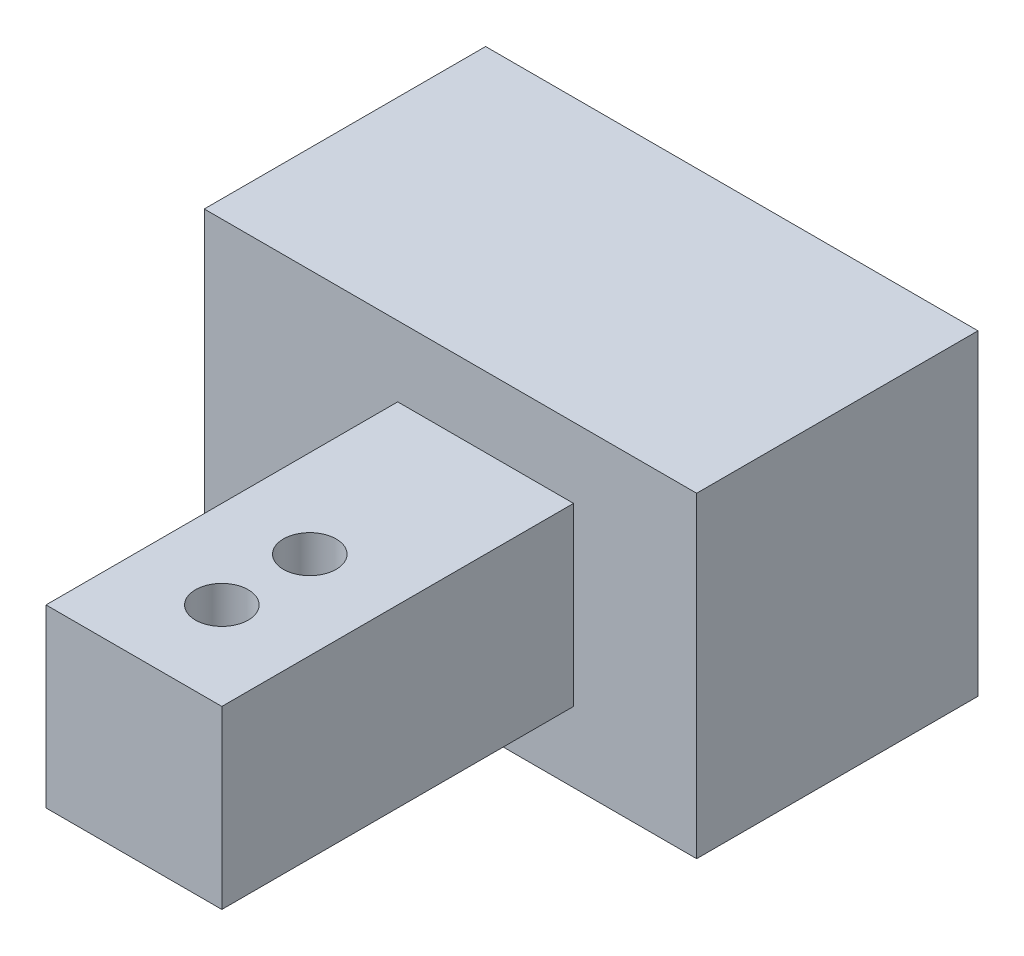
from build123d import *

# Parameters (mm, degrees)
SKETCH1_W           = 28
SKETCH1_H           = 16
BOSS_EXTRUDE1_DEPTH = 18
SKETCH3_W           = 10
SKETCH3_H           = 10
BOSS_EXTRUDE3_DEPTH = 20
SKETCH4_R           = 1.5
CUT_EXTRUDE1_DEPTH  = 20
SKETCH5_W           = 12
SKETCH5_H           = 14
CUT_EXTRUDE2_DEPTH  = 26


with BuildPart() as part:
    # Sketch1 → Boss-Extrude1 (new body)
    with BuildSketch(Plane(origin=(0, 0, 0), x_dir=(1, 0, 0), z_dir=(0, 1, 0))):
        with Locations((0.461538462, -2.646153846)):
            Rectangle(SKETCH1_W, SKETCH1_H)
    extrude(amount=BOSS_EXTRUDE1_DEPTH)

    # Sketch3 → Boss-Extrude3 (add)
    with BuildSketch(Plane.XY.offset(10.646153846)):
        with Locations((2.461538462, 9)):
            Rectangle(SKETCH3_W, SKETCH3_H)
    extrude(amount=BOSS_EXTRUDE3_DEPTH)

    # Sketch4 → Cut-Extrude1 (cut)
    with BuildSketch(Plane(origin=(0, 14, 0), x_dir=(1, 0, 0), z_dir=(0, 1, 0))):
        with Locations((2.461538462, -20.646153846)):
            Circle(SKETCH4_R)
        with Locations((2.461538462, -25.646153846)):
            Circle(SKETCH4_R)
    extrude(amount=-CUT_EXTRUDE1_DEPTH, mode=Mode.SUBTRACT)

    # Sketch5 → Cut-Extrude2 (cut)
    with BuildSketch(Plane.ZY.offset(13.538461538)):
        with Locations((2.646153846, 9)):
            Rectangle(SKETCH5_W, SKETCH5_H)
    extrude(amount=-CUT_EXTRUDE2_DEPTH, mode=Mode.SUBTRACT)


solid = part.part
